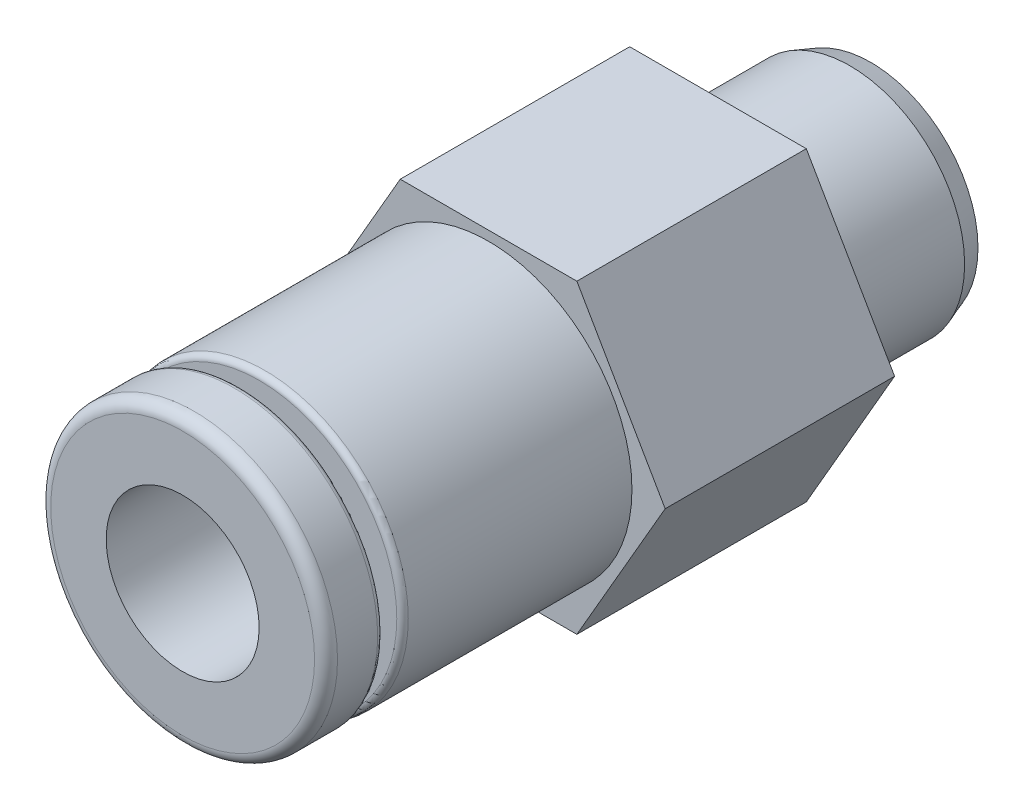
from build123d import *

# Parameters (mm, degrees)
ESQUISSE1_R        = 3
ESQUISSE1_R_2      = 1.25
BOSS_EXTRU_1_DEPTH = 4
CHANFREIN1_SIZE    = 0.2
CHANFREIN1_SIZE2   = 0.549495484
ESQUISSE2_R        = 2
BOSS_EXTRU_2_DEPTH = 6
ESQUISSE3_R        = 3.75
ESQUISSE3_R_2      = 2
BOSS_EXTRU_3_DEPTH = 8
CONG_3_R           = 0.3
ESQUISSE4_W        = 1.5
ESQUISSE4_H        = 0.5
CONG_4_R           = 0.3
CONG_5_R           = 0.15


with BuildPart() as part:
    # Esquisse1 → Boss.-Extru.1 (new body)
    with BuildSketch(Plane.XY):
        Circle(ESQUISSE1_R)
        Circle(ESQUISSE1_R_2, mode=Mode.SUBTRACT)
    extrude(amount=BOSS_EXTRU_1_DEPTH)

    # Chanfrein1
    chanfrein1_edges = [part.edges().sort_by_distance(p)[0] for p in [
        (-3, 0, 0),
    ]]
    chanfrein1_side = [part.faces().sort_by_distance(p)[0] for p in [
        (-2.915147186, 0, 0),
    ]]
    chamfer(chanfrein1_edges, length=CHANFREIN1_SIZE, length2=CHANFREIN1_SIZE2, reference=chanfrein1_side[0])

    # Esquisse2 → Boss.-Extru.2 (add)
    with BuildSketch(Plane.XY.offset(4)):
        Polygon((2.309401077, -4), (4.618802154, 0), (2.309401077, 4), (-2.309401077, 4), (-4.618802154, 0), (-2.309401077, -4), align=None)
        Circle(ESQUISSE2_R, mode=Mode.SUBTRACT)
    extrude(amount=BOSS_EXTRU_2_DEPTH)

    # Esquisse3 → Boss.-Extru.3 (add)
    with BuildSketch(Plane.XY.offset(10)):
        Circle(ESQUISSE3_R)
        Circle(ESQUISSE3_R_2, mode=Mode.SUBTRACT)
    extrude(amount=BOSS_EXTRU_3_DEPTH)

    # Congé3
    cong_3_edges = [part.edges().sort_by_distance(p)[0] for p in [
        (-3, 0, 4),
    ]]
    fillet(cong_3_edges, radius=CONG_3_R)

    # Esquisse4 → Enlèvement de matière-Révolution1 (revolve, cut)
    with BuildSketch(Plane(origin=(0, 0, 0), x_dir=(1, 0, 0), z_dir=(0, 1, 0))):
        with Locations((3, -16.25)):
            Rectangle(ESQUISSE4_W, ESQUISSE4_H)
    revolve(axis=Axis((0, 0, 52.241443479), (0, 0, -1)), mode=Mode.SUBTRACT)

    # Congé4
    cong_4_edges = [part.edges().sort_by_distance(p)[0] for p in [
        (-3.75, 0, 18),
    ]]
    fillet(cong_4_edges, radius=CONG_4_R)

    # Congé5
    cong_5_edges = [part.edges().sort_by_distance(p)[0] for p in [
        (-3.75, 0, 16),
        (-3.75, 0, 16.5),
    ]]
    fillet(cong_5_edges, radius=CONG_5_R)


solid = part.part
